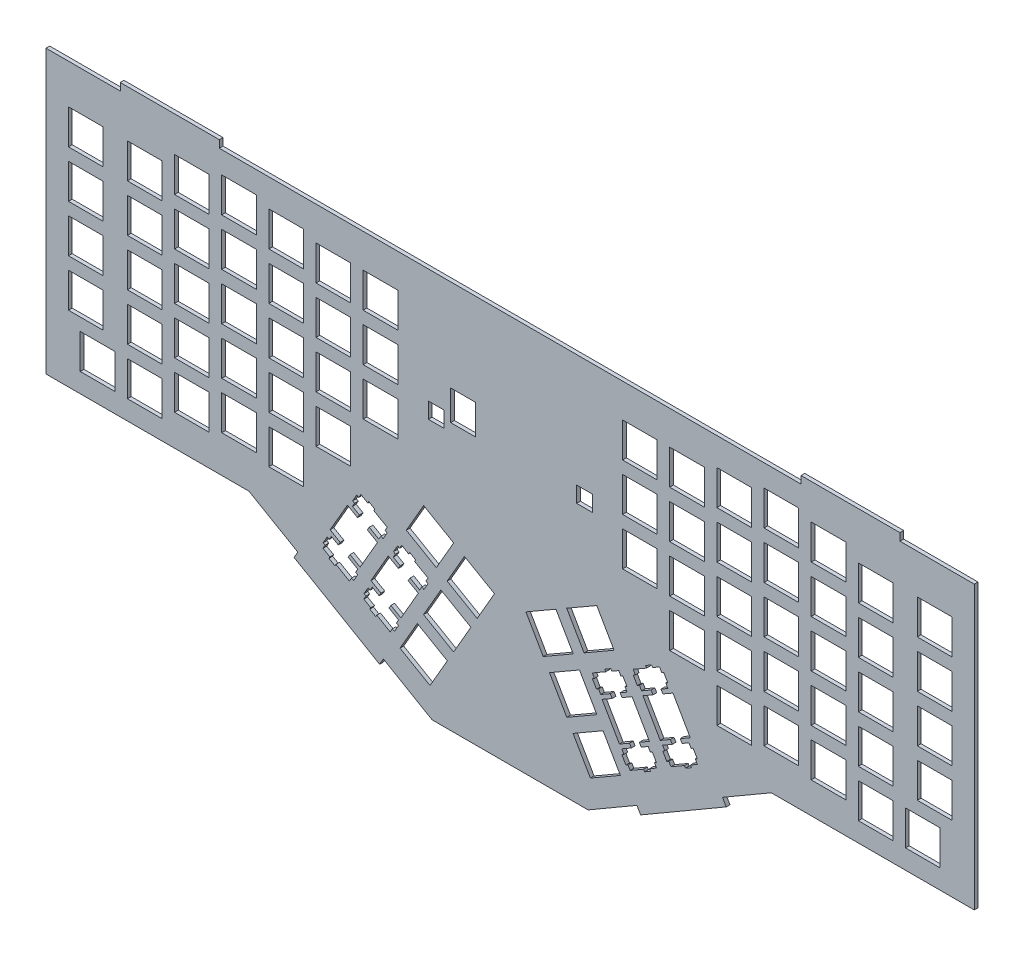
from build123d import *

# Parameters (mm, degrees)
MODEL_W              = 371.4749154
MODEL_H              = 142.533331
MODEL_W_2            = 13.9994
MODEL_H_2            = 14.0007
MODEL_W_3            = 13.9993
MODEL_W_4            = 13.999
MODEL_H_3            = 13.9993
MODEL_W_5            = 13.99954
MODEL_W_6            = 14
MODEL_H_4            = 13.999
MODEL_H_5            = 14.001
MODEL_H_6            = 14
BOSS_EXTRUDE1_DEPTH  = 1.5
SKETCH1_W            = 371.4749154
SKETCH1_H            = 1.5
BOSS_EXTRUDE2_DEPTH  = 5.46
SKETCH2_W            = 371.4749154
SKETCH2_H            = 1.5
BOSS_EXTRUDE3_DEPTH  = 8.2
SKETCH6_W            = 1.5
SKETCH6_H            = 156.193331
BOSS_EXTRUDE5_DEPTH  = 2
SKETCH9_W            = 1.5
SKETCH9_H            = 156.193331
BOSS_EXTRUDE8_DEPTH  = 10
SKETCH7_W            = 383.4749154
SKETCH7_H            = 1.5
BOSS_EXTRUDE9_DEPTH  = 10
CUT_EXTRUDE1_DEPTH   = 10
SKETCH4_W            = 6.4
SKETCH4_H            = 6.4
SKETCH4_W_2          = 10
SKETCH4_H_2          = 12.12
SKETCH4_H_3          = 6.408848303
CUT_EXTRUDE2_DEPTH   = 2
SKETCH11_W           = 40
SKETCH11_H           = 1.5
BOSS_EXTRUDE10_DEPTH = 3
BOSS_EXTRUDE11_DEPTH = 3
BOSS_EXTRUDE12_DEPTH = 3


with BuildPart() as part:
    # Model → Boss-Extrude1 (new body)
    with BuildSketch(Plane.XY):
        with Locations((185.8325423, 71.5133345)):
            Rectangle(MODEL_W, MODEL_H)
        Polygon((141.314, 10.6977), (153.439, 3.69729), (160.438, 15.8213), (148.314, 22.8217), align=None, mode=Mode.SUBTRACT)
        Polygon((211.224, 15.8213), (218.225, 3.69729), (230.35, 10.6977), (223.35, 22.8217), align=None, mode=Mode.SUBTRACT)
        Polygon((141.126, 45.533), (140.33, 45.992), (138.679, 43.1341), (139.477, 42.6752), (138.614, 41.1812), (141.412, 39.5661), (140.648, 38.2461), (136.579, 40.5955), (129.578, 28.4716), (133.649, 26.1221), (132.887, 24.8006), (130.09, 26.4156), (129.227, 24.9218), (128.429, 25.3821), (126.78, 22.524), (127.576, 22.0638), (126.715, 20.57), (129.512, 18.9549), (129.099, 18.2411), (131.524, 16.841), (131.936, 17.5548), (137.367, 14.4198), (138.228, 15.9136), (139.077, 15.423), (140.728, 18.2811), (139.879, 18.773), (140.742, 20.2654), (136.871, 22.5006), (137.633, 23.8221), (141.702, 21.4712), (148.703, 33.5952), (144.632, 35.9463), (145.396, 37.2664), (149.266, 35.0311), (150.129, 36.5248), (150.978, 36.0345), (152.628, 38.8923), (151.778, 39.3831), (152.641, 40.8767), (147.212, 44.0119), (147.624, 44.7269), (145.198, 46.1271), (144.786, 45.412), (141.989, 47.027), align=None, mode=Mode.SUBTRACT)
        Polygon((226.876, 45.412), (226.464, 46.1271), (224.04, 44.7269), (224.452, 44.0119), (219.021, 40.8767), (219.884, 39.3831), (219.035, 38.8923), (220.686, 36.0345), (221.535, 36.5248), (222.396, 35.0311), (226.267, 37.2664), (227.031, 35.9463), (222.961, 33.5952), (229.96, 21.4712), (234.031, 23.8221), (234.793, 22.5006), (230.922, 20.2654), (231.785, 18.773), (230.936, 18.2811), (232.585, 15.423), (233.434, 15.9136), (234.297, 14.4198), (239.726, 17.5548), (240.14, 16.841), (242.565, 18.2411), (242.152, 18.9549), (244.949, 20.57), (244.086, 22.0638), (244.883, 22.524), (243.233, 25.3821), (242.437, 24.9218), (241.573, 26.4156), (238.777, 24.8006), (238.014, 26.1221), (242.084, 28.4716), (235.085, 40.5955), (231.014, 38.2461), (230.251, 39.5661), (233.048, 41.1812), (232.187, 42.6752), (232.984, 43.1341), (231.334, 45.992), (230.536, 45.533), (229.674, 47.027), align=None, mode=Mode.SUBTRACT)
        Polygon((150.839, 27.1942), (162.964, 20.1952), (169.963, 32.3191), (157.839, 39.3196), align=None, mode=Mode.SUBTRACT)
        Polygon((201.699, 32.3191), (208.7, 20.1952), (220.825, 27.1942), (213.825, 39.3196), align=None, mode=Mode.SUBTRACT)
        Polygon((124.627, 55.058), (123.832, 55.517), (122.182, 52.6591), (122.979, 52.2002), (122.116, 50.7062), (124.912, 49.0911), (124.15, 47.7711), (120.081, 50.1206), (113.08, 37.9966), (117.151, 35.6471), (116.389, 34.3256), (113.592, 35.9406), (112.729, 34.4468), (111.933, 34.9071), (110.283, 32.0491), (111.078, 31.5888), (110.217, 30.095), (113.013, 28.4799), (112.601, 27.7661), (115.025, 26.366), (115.438, 27.0798), (120.869, 23.9448), (121.731, 25.4386), (122.579, 24.948), (124.229, 27.806), (123.38, 28.2966), (124.244, 29.7904), (120.373, 32.0256), (121.135, 33.3471), (125.204, 30.9962), (132.205, 43.12), (128.134, 45.4713), (128.898, 46.7914), (132.769, 44.5562), (133.631, 46.0498), (134.48, 45.5595), (136.13, 48.4173), (135.281, 48.9081), (136.143, 50.4017), (130.714, 53.5368), (131.126, 54.2519), (128.702, 55.6521), (128.288, 54.937), (125.491, 56.552), align=None, mode=Mode.SUBTRACT)
        Polygon((243.374, 54.937), (242.962, 55.6521), (240.538, 54.2519), (240.95, 53.5368), (235.519, 50.4017), (236.383, 48.9081), (235.533, 48.4173), (237.184, 45.5595), (238.033, 46.0498), (238.894, 44.5562), (242.765, 46.7914), (243.528, 45.4713), (239.457, 43.12), (246.458, 30.9962), (250.527, 33.3471), (251.291, 32.0256), (247.42, 29.7904), (248.283, 28.2966), (247.434, 27.806), (249.083, 24.948), (249.932, 25.4386), (250.795, 23.9448), (256.224, 27.0798), (256.638, 26.366), (259.062, 27.7661), (258.65, 28.4799), (261.447, 30.095), (260.584, 31.5888), (261.381, 32.0491), (259.73, 34.9071), (258.935, 34.4468), (258.072, 35.9406), (255.275, 34.3256), (254.51, 35.6471), (258.582, 37.9966), (251.583, 50.1206), (247.512, 47.7711), (246.75, 49.0911), (249.546, 50.7062), (248.685, 52.2002), (249.48, 52.6591), (247.831, 55.517), (247.034, 55.058), (246.172, 56.552), align=None, mode=Mode.SUBTRACT)
        Polygon((160.364, 43.6922), (172.489, 36.6931), (179.488, 48.817), (167.364, 55.8176), align=None, mode=Mode.SUBTRACT)
        Polygon((192.174, 48.817), (199.175, 36.6931), (211.3, 43.6922), (204.3, 55.8176), align=None, mode=Mode.SUBTRACT)
        with Locations((19.1444, 49.91255)):
            Rectangle(MODEL_W_2, MODEL_H_2, mode=Mode.SUBTRACT)
        with Locations((38.19435, 49.91255)):
            Rectangle(MODEL_W_3, MODEL_H_2, mode=Mode.SUBTRACT)
        with Locations((333.4695, 49.91255)):
            Rectangle(MODEL_W_4, MODEL_H_2, mode=Mode.SUBTRACT)
        with Locations((352.5195, 49.91255)):
            Rectangle(MODEL_W_4, MODEL_H_2, mode=Mode.SUBTRACT)
        Polygon((143.866, 53.2172), (155.991, 46.2181), (162.99, 58.342), (150.865, 65.3426), align=None, mode=Mode.SUBTRACT)
        Polygon((208.672, 58.342), (215.672, 46.2181), (227.798, 53.2172), (220.798, 65.3426), align=None, mode=Mode.SUBTRACT)
        with Locations((57.24435, 54.67435)):
            Rectangle(MODEL_W_3, MODEL_H_3, mode=Mode.SUBTRACT)
        with Locations((95.34435, 54.67435)):
            Rectangle(MODEL_W_3, MODEL_H_3, mode=Mode.SUBTRACT)
        with Locations((276.3195, 54.67435)):
            Rectangle(MODEL_W_4, MODEL_H_3, mode=Mode.SUBTRACT)
        with Locations((314.4195, 54.67435)):
            Rectangle(MODEL_W_4, MODEL_H_3, mode=Mode.SUBTRACT)
        with Locations((76.29435, 57.05565)):
            Rectangle(MODEL_W_3, MODEL_H_3, mode=Mode.SUBTRACT)
        with Locations((295.3695, 57.05565)):
            Rectangle(MODEL_W_4, MODEL_H_3, mode=Mode.SUBTRACT)
        with Locations((14.38193, 68.96255)):
            Rectangle(MODEL_W_5, MODEL_H_2, mode=Mode.SUBTRACT)
        with Locations((38.19435, 68.96255)):
            Rectangle(MODEL_W_3, MODEL_H_2, mode=Mode.SUBTRACT)
        with Locations((333.4695, 68.96255)):
            Rectangle(MODEL_W_4, MODEL_H_2, mode=Mode.SUBTRACT)
        with Locations((357.282, 68.96255)):
            Rectangle(MODEL_W_6, MODEL_H_2, mode=Mode.SUBTRACT)
        with Locations((114.3945, 71.34315)):
            Rectangle(MODEL_W_4, MODEL_H_3, mode=Mode.SUBTRACT)
        with Locations((257.2695, 71.34315)):
            Rectangle(MODEL_W_4, MODEL_H_3, mode=Mode.SUBTRACT)
        with Locations((57.24435, 73.72435)):
            Rectangle(MODEL_W_3, MODEL_H_3, mode=Mode.SUBTRACT)
        with Locations((95.34435, 73.72435)):
            Rectangle(MODEL_W_3, MODEL_H_3, mode=Mode.SUBTRACT)
        with Locations((276.3195, 73.72435)):
            Rectangle(MODEL_W_4, MODEL_H_3, mode=Mode.SUBTRACT)
        with Locations((314.4195, 73.72435)):
            Rectangle(MODEL_W_4, MODEL_H_3, mode=Mode.SUBTRACT)
        with Locations((76.29435, 76.10565)):
            Rectangle(MODEL_W_3, MODEL_H_3, mode=Mode.SUBTRACT)
        with Locations((295.3695, 76.10565)):
            Rectangle(MODEL_W_4, MODEL_H_3, mode=Mode.SUBTRACT)
        with Locations((14.38193, 88.01255)):
            Rectangle(MODEL_W_5, MODEL_H_2, mode=Mode.SUBTRACT)
        with Locations((38.19435, 88.01255)):
            Rectangle(MODEL_W_3, MODEL_H_2, mode=Mode.SUBTRACT)
        with Locations((333.4695, 88.01255)):
            Rectangle(MODEL_W_4, MODEL_H_2, mode=Mode.SUBTRACT)
        with Locations((357.282, 88.01255)):
            Rectangle(MODEL_W_6, MODEL_H_2, mode=Mode.SUBTRACT)
        with Locations((114.3945, 90.39315)):
            Rectangle(MODEL_W_4, MODEL_H_3, mode=Mode.SUBTRACT)
        with Locations((133.4445, 90.39315)):
            Rectangle(MODEL_W_4, MODEL_H_3, mode=Mode.SUBTRACT)
        with Locations((238.2195, 90.39315)):
            Rectangle(MODEL_W_4, MODEL_H_3, mode=Mode.SUBTRACT)
        with Locations((257.2695, 90.39315)):
            Rectangle(MODEL_W_4, MODEL_H_3, mode=Mode.SUBTRACT)
        with Locations((57.24435, 92.77435)):
            Rectangle(MODEL_W_3, MODEL_H_3, mode=Mode.SUBTRACT)
        with Locations((95.34435, 92.77435)):
            Rectangle(MODEL_W_3, MODEL_H_3, mode=Mode.SUBTRACT)
        with Locations((276.3195, 92.77435)):
            Rectangle(MODEL_W_4, MODEL_H_3, mode=Mode.SUBTRACT)
        with Locations((314.4195, 92.77435)):
            Rectangle(MODEL_W_4, MODEL_H_3, mode=Mode.SUBTRACT)
        with Locations((76.29435, 95.1555)):
            Rectangle(MODEL_W_3, MODEL_H_4, mode=Mode.SUBTRACT)
        with Locations((295.3695, 95.1555)):
            Rectangle(MODEL_W_4, MODEL_H_4, mode=Mode.SUBTRACT)
        with Locations((14.38193, 107.0625)):
            Rectangle(MODEL_W_5, MODEL_H_5, mode=Mode.SUBTRACT)
        with Locations((38.19435, 107.0625)):
            Rectangle(MODEL_W_3, MODEL_H_5, mode=Mode.SUBTRACT)
        with Locations((333.4695, 107.0625)):
            Rectangle(MODEL_W_4, MODEL_H_5, mode=Mode.SUBTRACT)
        with Locations((357.282, 107.0625)):
            Rectangle(MODEL_W_6, MODEL_H_5, mode=Mode.SUBTRACT)
        with Locations((114.3945, 109.443)):
            Rectangle(MODEL_W_4, MODEL_H_6, mode=Mode.SUBTRACT)
        with Locations((133.4445, 109.443)):
            Rectangle(MODEL_W_4, MODEL_H_6, mode=Mode.SUBTRACT)
        with Locations((238.2195, 109.443)):
            Rectangle(MODEL_W_4, MODEL_H_6, mode=Mode.SUBTRACT)
        with Locations((257.2695, 109.443)):
            Rectangle(MODEL_W_4, MODEL_H_6, mode=Mode.SUBTRACT)
        with Locations((57.24435, 111.8245)):
            Rectangle(MODEL_W_3, MODEL_H_4, mode=Mode.SUBTRACT)
        with Locations((95.34435, 111.8245)):
            Rectangle(MODEL_W_3, MODEL_H_4, mode=Mode.SUBTRACT)
        with Locations((276.3195, 111.8245)):
            Rectangle(MODEL_W_4, MODEL_H_4, mode=Mode.SUBTRACT)
        with Locations((314.4195, 111.8245)):
            Rectangle(MODEL_W_4, MODEL_H_4, mode=Mode.SUBTRACT)
        with Locations((76.29435, 114.2055)):
            Rectangle(MODEL_W_3, MODEL_H_4, mode=Mode.SUBTRACT)
        with Locations((295.3695, 114.2055)):
            Rectangle(MODEL_W_4, MODEL_H_4, mode=Mode.SUBTRACT)
        with Locations((14.38193, 126.1125)):
            Rectangle(MODEL_W_5, MODEL_H_5, mode=Mode.SUBTRACT)
        with Locations((38.19435, 126.1125)):
            Rectangle(MODEL_W_3, MODEL_H_5, mode=Mode.SUBTRACT)
        with Locations((333.4695, 126.1125)):
            Rectangle(MODEL_W_4, MODEL_H_5, mode=Mode.SUBTRACT)
        with Locations((357.282, 126.1125)):
            Rectangle(MODEL_W_6, MODEL_H_5, mode=Mode.SUBTRACT)
        with Locations((114.3945, 128.493)):
            Rectangle(MODEL_W_4, MODEL_H_6, mode=Mode.SUBTRACT)
        with Locations((133.4445, 128.493)):
            Rectangle(MODEL_W_4, MODEL_H_6, mode=Mode.SUBTRACT)
        with Locations((238.2195, 128.493)):
            Rectangle(MODEL_W_4, MODEL_H_6, mode=Mode.SUBTRACT)
        with Locations((257.2695, 128.493)):
            Rectangle(MODEL_W_4, MODEL_H_6, mode=Mode.SUBTRACT)
        with Locations((57.24435, 130.8745)):
            Rectangle(MODEL_W_3, MODEL_H_4, mode=Mode.SUBTRACT)
        with Locations((95.34435, 130.8745)):
            Rectangle(MODEL_W_3, MODEL_H_4, mode=Mode.SUBTRACT)
        with Locations((276.3195, 130.8745)):
            Rectangle(MODEL_W_4, MODEL_H_4, mode=Mode.SUBTRACT)
        with Locations((314.4195, 130.8745)):
            Rectangle(MODEL_W_4, MODEL_H_4, mode=Mode.SUBTRACT)
        with Locations((76.29435, 133.2555)):
            Rectangle(MODEL_W_3, MODEL_H_4, mode=Mode.SUBTRACT)
        with Locations((295.3695, 133.2555)):
            Rectangle(MODEL_W_4, MODEL_H_4, mode=Mode.SUBTRACT)
    extrude(amount=BOSS_EXTRUDE1_DEPTH)

    # Sketch1 → Boss-Extrude2 (add)
    with BuildSketch(Plane(origin=(0, 142.78, 0), x_dir=(1, 0, 0), z_dir=(0, 1, 0))):
        with Locations((185.8325423, -0.75)):
            Rectangle(SKETCH1_W, SKETCH1_H)
    extrude(amount=BOSS_EXTRUDE2_DEPTH)

    # Sketch2 → Boss-Extrude3 (add)
    with BuildSketch(Plane.XZ.offset(-0.246669)):
        with Locations((185.8325423, 0.75)):
            Rectangle(SKETCH2_W, SKETCH2_H)
    extrude(amount=BOSS_EXTRUDE3_DEPTH)

    # Sketch6 → Boss-Extrude5 (add)
    with BuildSketch(Plane(origin=(371.57, 0, 0), x_dir=(0, 0, -1), z_dir=(1, 0, 0))):
        with Locations((-0.75, 70.1433345)):
            Rectangle(SKETCH6_W, SKETCH6_H)
    extrude(amount=BOSS_EXTRUDE5_DEPTH)

    # Sketch9 → Boss-Extrude8 (add)
    with BuildSketch(Plane.ZY.offset(-0.0950846)):
        with Locations((0.75, 70.1433345)):
            Rectangle(SKETCH9_W, SKETCH9_H)
    extrude(amount=BOSS_EXTRUDE8_DEPTH)

    # Sketch7 → Boss-Extrude9 (add)
    with BuildSketch(Plane(origin=(0, 148.24, 0), x_dir=(1, 0, 0), z_dir=(0, 1, 0))):
        with Locations((181.8325423, -0.75)):
            Rectangle(SKETCH7_W, SKETCH7_H)
    extrude(amount=BOSS_EXTRUDE9_DEPTH)

    # Sketch10 → Cut-Extrude1 (cut)
    with BuildSketch(Plane(origin=(0, 0, 0), x_dir=(-1, 0, 0), z_dir=(0, 0, -1))):
        Polygon((9.9049154, -7.953331), (9.9049154, 158.24), (-373.57, 158.24), (-373.57, 149.098786614), (-373.57, -7.953331), (-154.311746614, -7.953331), align=None)
        Polygon((-373.311746614, 149.098786614), (1.688253386, 149.098786614), (1.688253386, 35.098786614), (-80.311746614, 35.098786614), (-154.311746614, -7.901213386), (-217.311746614, -7.901213386), (-291.311746614, 35.098786614), (-373.311746614, 35.098786614), align=None, mode=Mode.SUBTRACT)
    extrude(amount=-CUT_EXTRUDE1_DEPTH, mode=Mode.SUBTRACT)

    # Sketch4 → Cut-Extrude2 (cut)
    with BuildSketch(Plane.XY.offset(1.5)):
        with Locations((155.961746614, 99.688786614)):
            Rectangle(SKETCH4_W, SKETCH4_H)
        with Locations((166.796746614, 105.898786614)):
            Rectangle(SKETCH4_W_2, SKETCH4_H_2)
        with Locations((215.861746614, 100.238786615)):
            Rectangle(SKETCH4_W, SKETCH4_H_3)
    extrude(amount=-CUT_EXTRUDE2_DEPTH, mode=Mode.SUBTRACT)

    # Sketch11 → Boss-Extrude10 (add)
    with BuildSketch(Plane(origin=(0, 149.098786614, 0), x_dir=(1, 0, 0), z_dir=(0, 1, 0))):
        with Locations((48.311746614, -0.75)):
            Rectangle(SKETCH11_W, SKETCH11_H)
        with Locations((323.311746614, -0.75)):
            Rectangle(SKETCH11_W, SKETCH11_H)
    extrude(amount=BOSS_EXTRUDE10_DEPTH)

    # Sketch13 → Boss-Extrude11 (add)
    with BuildSketch(Plane(origin=(35.519557474, 61.126680304, 0), x_dir=(0.864625232, -0.502417365, 0), z_dir=(-0.502417365, -0.864625232, 0))):
        Polygon((94.598429601, 1.5), (114.598429601, 1.5), (114.598429601, 0), (74.598429601, 0), (74.598429601, 1.5), align=None)
    extrude(amount=BOSS_EXTRUDE11_DEPTH)

    # Sketch14 → Boss-Extrude12 (add)
    with BuildSketch(Plane(origin=(58.286836926, -100.307579826, 0), x_dir=(0.864625232, 0.502417365, 0), z_dir=(0.502417365, -0.864625232, 0))):
        Polygon((226.716619448, 1.5), (246.716619448, 1.5), (246.716619448, 0), (206.716619448, 0), (206.716619448, 1.5), align=None)
    extrude(amount=BOSS_EXTRUDE12_DEPTH)


solid = part.part
